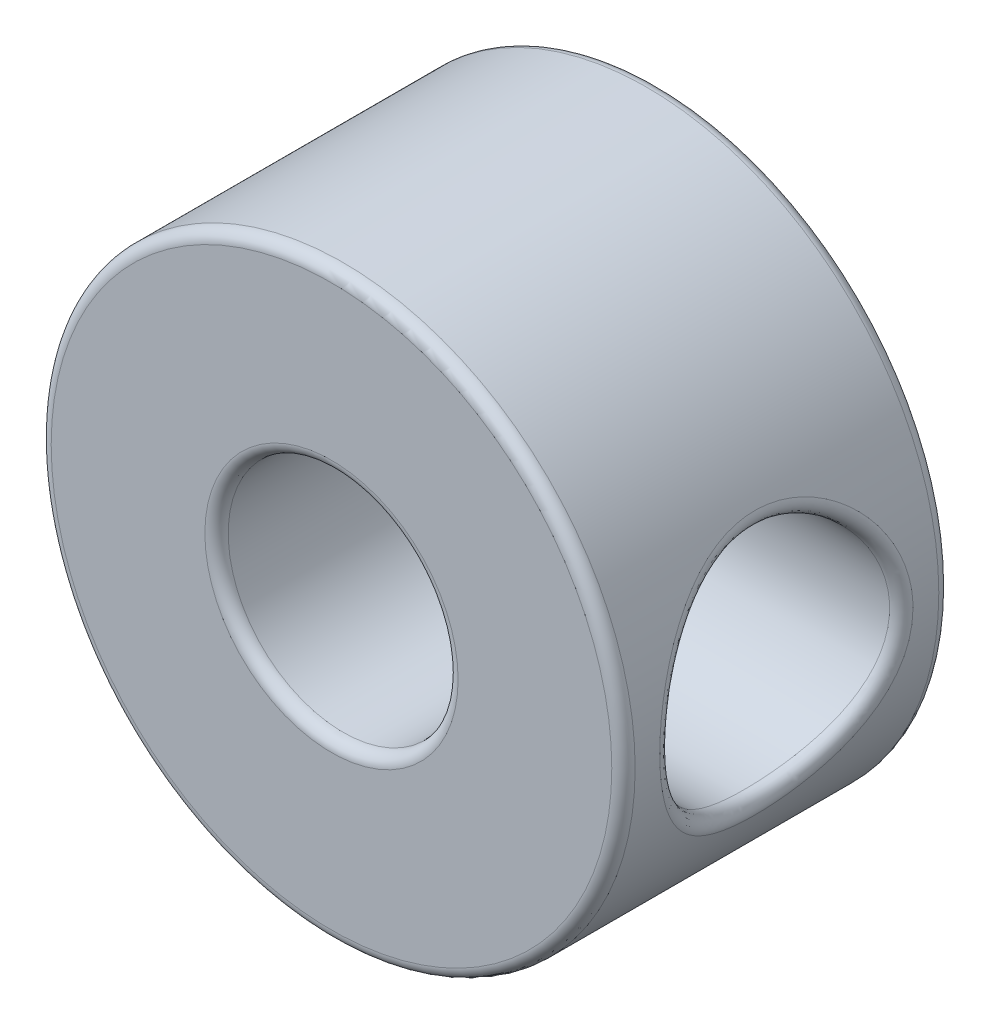
from build123d import *

# Parameters (mm, degrees)
SKETCH2_R           = 6.35
BOSS_EXTRUDE1_DEPTH = 7.112
SKETCH3_R           = 2.5
CUT_EXTRUDE1_DEPTH  = 19.05
SKETCH4_R           = 2.499999953
CUT_EXTRUDE2_DEPTH  = 19.05
FILLET1_R           = 0.254


with BuildPart() as part:
    # Sketch2 → Boss-Extrude1 (new body)
    with BuildSketch(Plane.XY):
        Circle(SKETCH2_R)
    extrude(amount=BOSS_EXTRUDE1_DEPTH)

    # Sketch3 → Cut-Extrude1 (cut)
    with BuildSketch(Plane.XY.offset(7.112)):
        Circle(SKETCH3_R)
    extrude(amount=-CUT_EXTRUDE1_DEPTH, mode=Mode.SUBTRACT)

    # Sketch4 → Cut-Extrude2 (cut)
    with BuildSketch(Plane(origin=(0, 0, 0), x_dir=(0, 0, -1), z_dir=(1, 0, 0))):
        with Locations((-3.5687, 0)):
            Circle(SKETCH4_R)
    extrude(amount=CUT_EXTRUDE2_DEPTH, mode=Mode.SUBTRACT)

    # Fillet1
    fillet1_edges = [part.edges().sort_by_distance(p)[0] for p in [
        (5.837165428, 2.499999953, 3.5687),
        (-6.35, 0, 0),
        (-6.35, 0, 7.112),
        (-2.5, 0, 0),
        (-2.5, 0, 7.112),
    ]]
    fillet(fillet1_edges, radius=FILLET1_R)


solid = part.part
